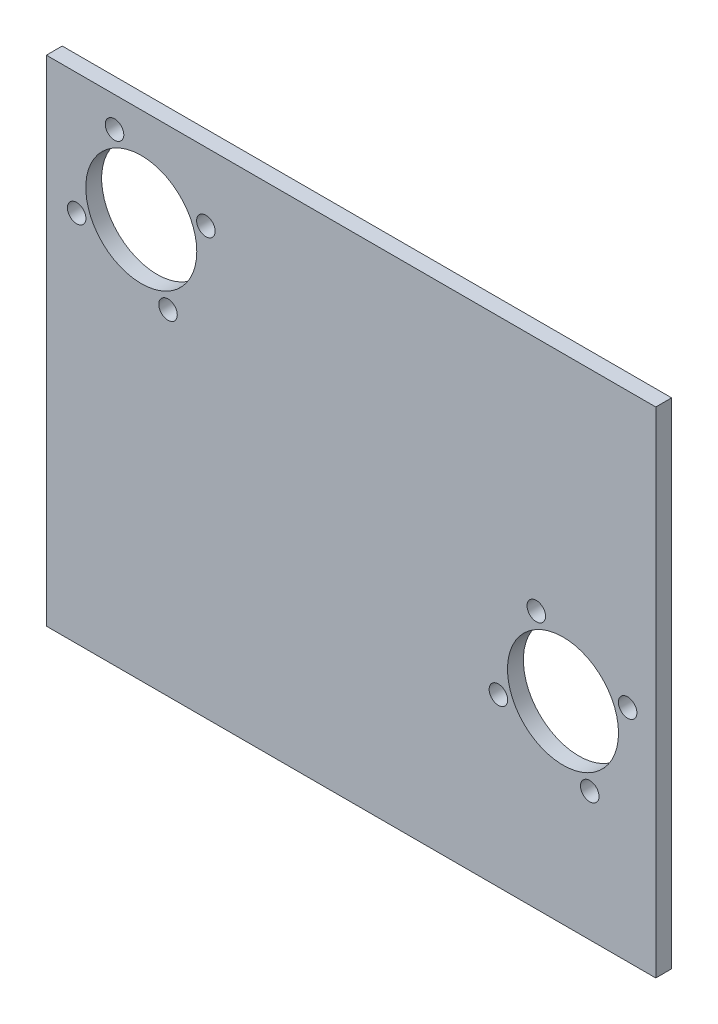
from build123d import *

# Parameters (mm, degrees)
SKETCH1_W           = 122
SKETCH1_H           = 99
SKETCH1_R           = 11.1125
SKETCH1_R_2         = 1.8542
BOSS_EXTRUDE1_DEPTH = 3.175


with BuildPart() as part:
    # Sketch1 → Boss-Extrude1 (new body)
    with BuildSketch(Plane.XY):
        with Locations((42, -30.5)):
            Rectangle(SKETCH1_W, SKETCH1_H)
        Circle(SKETCH1_R, mode=Mode.SUBTRACT)
        with Locations((-5.352449154, 12.936432586)):
            Circle(SKETCH1_R_2, mode=Mode.SUBTRACT)
        with Locations((-12.936432586, -5.352449154)):
            Circle(SKETCH1_R_2, mode=Mode.SUBTRACT)
        with Locations((12.936432586, 5.352449154)):
            Circle(SKETCH1_R_2, mode=Mode.SUBTRACT)
        with Locations((5.352449154, -12.936432586)):
            Circle(SKETCH1_R_2, mode=Mode.SUBTRACT)
        with Locations((84.431124445, -41.275)):
            Circle(SKETCH1_R, mode=Mode.SUBTRACT)
        with Locations((79.07867529, -28.338567414)):
            Circle(SKETCH1_R_2, mode=Mode.SUBTRACT)
        with Locations((71.494691859, -46.627449154)):
            Circle(SKETCH1_R_2, mode=Mode.SUBTRACT)
        with Locations((89.783573599, -54.211432586)):
            Circle(SKETCH1_R_2, mode=Mode.SUBTRACT)
        with Locations((97.367557031, -35.922550846)):
            Circle(SKETCH1_R_2, mode=Mode.SUBTRACT)
    extrude(amount=-BOSS_EXTRUDE1_DEPTH)


solid = part.part
